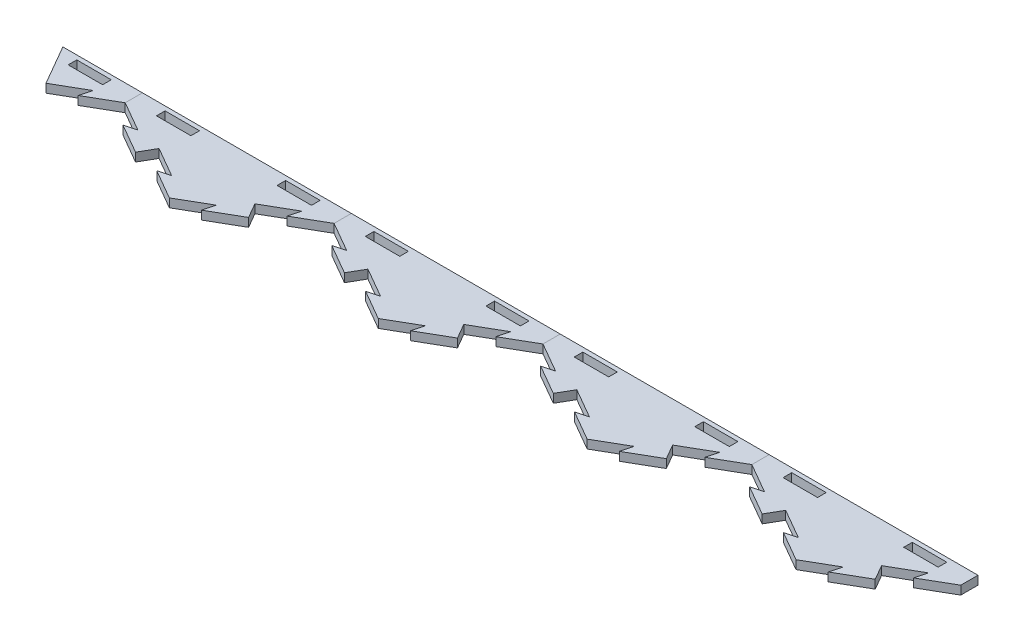
from build123d import *

# Parameters (mm, degrees)
BOSS_EXTRUDE1_DEPTH = 6.35
CUT_EXTRUDE4_DEPTH  = 155.110195964
BOSS_EXTRUDE4_DEPTH = 6.35
CIRPATTERN1_COUNT   = 2
CIRPATTERN1_ANGLE   = 60
SKETCH12_W          = 153.979316792
SKETCH12_H          = 120.65
CUT_EXTRUDE5_DEPTH  = 155.110195964
SKETCH13_W          = 25.4
SKETCH13_H          = 6.35
CUT_EXTRUDE6_DEPTH  = 90.126497182
LPATTERN1_COUNT     = 5
LPATTERN1_PITCH     = 153.979316882
LPATTERN1_2_COUNT   = 2
LPATTERN1_2_PITCH   = 153.979316882
SKETCH14_W          = 25.4
SKETCH14_H          = 6.35
CUT_EXTRUDE7_DEPTH  = 695.360232872
SKETCH15_W          = 58.658787349
SKETCH15_H          = 40.424261314
CUT_EXTRUDE8_DEPTH  = 600.270912242


with BuildPart() as part:
    # Sketch1 → Boss-Extrude1 (new body)
    with BuildSketch(Plane(origin=(0, 0, 0), x_dir=(1, 0, 0), z_dir=(0, 1, 0))):
        Polygon((-76.989658396, 0), (0, -44.45), (76.989658396, 0), (76.989658396, 88.9), (0, 133.35), (-76.989658396, 88.9), align=None)
    extrude(amount=-BOSS_EXTRUDE1_DEPTH)

    # Sketch10 → Cut-Extrude4 (cut, through all)
    with BuildSketch(Plane(origin=(0, 0, 0), x_dir=(1, 0, 0), z_dir=(0, 1, 0))):
        Polygon((-21.997045256, -31.75), (-13.322783942, -29.425738686), (-35.319829198, -16.725738686), (-38.494829198, -22.225), align=None)
    cut_extrude4 = extrude(amount=-CUT_EXTRUDE4_DEPTH, mode=Mode.SUBTRACT)

    # Sketch11 → Boss-Extrude4 (add)
    with BuildSketch(Plane(origin=(0, 0, 0), x_dir=(1, 0, 0), z_dir=(0, 1, 0))):
        Polygon((-38.494829198, -22.225), (-41.669829198, -27.724261314), (-63.666874454, -15.024261314), (-54.99261314, -12.7), align=None)
    boss_extrude4 = extrude(amount=-BOSS_EXTRUDE4_DEPTH)

    # CirPattern1: Cut-Extrude4, Boss-Extrude4 ×2 about axis
    cirpattern1_axis = Axis((0, 0, -44.45), (0, 1, 0))
    add([cut_extrude4.rotate(cirpattern1_axis, i * CIRPATTERN1_ANGLE / (CIRPATTERN1_COUNT - 1)) for i in range(1, CIRPATTERN1_COUNT)], mode=Mode.SUBTRACT)
    add([boss_extrude4.rotate(cirpattern1_axis, i * CIRPATTERN1_ANGLE / (CIRPATTERN1_COUNT - 1)) for i in range(1, CIRPATTERN1_COUNT)])

    # Sketch12 → Cut-Extrude5 (cut, through all)
    with BuildSketch(Plane(origin=(0, 0, 0), x_dir=(1, 0, 0), z_dir=(0, 1, 0))):
        with Locations((0, 73.025)):
            Rectangle(SKETCH12_W, SKETCH12_H)
    extrude(amount=-CUT_EXTRUDE5_DEPTH, mode=Mode.SUBTRACT)

    # Sketch13 → Cut-Extrude6 (cut, through all)
    with BuildSketch(Plane(origin=(0, 0, 0), x_dir=(1, 0, 0), z_dir=(0, 1, 0))):
        with Locations((-44.45, 6.35)):
            Rectangle(SKETCH13_W, SKETCH13_H)
        with Locations((44.45, 6.35)):
            Rectangle(SKETCH13_W, SKETCH13_H)
    extrude(amount=-CUT_EXTRUDE6_DEPTH, mode=Mode.SUBTRACT)


with BuildPart() as lpattern1_1:
    # LPattern1: pattern copy
    add(part.part.moved(Location(Vector(1, 0, 0) * (1 * LPATTERN1_PITCH))))


with BuildPart() as lpattern1_2:
    # LPattern1: pattern copy
    add(part.part.moved(Location(Vector(1, 0, 0) * (2 * LPATTERN1_PITCH))))


with BuildPart() as lpattern1_3:
    # LPattern1: pattern copy
    add(part.part.moved(Location(Vector(1, 0, 0) * (3 * LPATTERN1_PITCH))))


with BuildPart() as lpattern1_4:
    # LPattern1: pattern copy
    add(part.part.moved(Location(Vector(1, 0, 0) * (4 * LPATTERN1_PITCH))))


with BuildPart() as lpattern1_2_1:
    # LPattern1 2: pattern copy
    add(part.part.moved(Location(Vector(-1, 0, 0) * (1 * LPATTERN1_2_PITCH))))


with BuildPart() as cut_extrude7_tool:
    # Sketch14 → Cut-Extrude7 (new, through all)
    # profile 1 of 2: a face of its own
    with BuildSketch(Plane(origin=(0, 0, 0), x_dir=(1, 0, 0), z_dir=(0, 1, 0))):
        Polygon((593.920222272, -31.75), (615.917267528, -44.45), (637.914312784, -31.75), (635.59005147, -40.424261314), (657.587096726, -27.724261314), (651.237096726, -16.725738686), (673.234141982, -4.025738686), (670.909880668, -12.7), (692.906925924, 0), (692.906925924, 12.7), (597.586396481, 12.7), (580.59743833, -16.725738686), (602.594483586, -29.425738686), align=None)
        with Locations((660.367267528, 6.35)):
            Rectangle(SKETCH14_W, SKETCH14_H, mode=Mode.SUBTRACT)
    # profile 2 of 2: a face of its own
    with BuildSketch(Plane(origin=(0, 0, 0), x_dir=(1, 0, 0), z_dir=(0, 1, 0))):
        Polygon((-230.968975278, -44.45), (-153.979316882, -44.45), (-134.30653294, -40.424261314), (-112.309487684, -27.724261314), (-135.648445835, 12.7), (-230.968975278, 12.7), align=None)
    extrude(amount=-CUT_EXTRUDE7_DEPTH)


with BuildPart() as lpattern1_4_1:
    add(lpattern1_4.part)

    # Cut-Extrude7: cut by cut_extrude7_tool
    add(cut_extrude7_tool.part, mode=Mode.SUBTRACT)

    # Sketch15 → Cut-Extrude8 (cut, through all)
    with BuildSketch(Plane(origin=(0, 0, 0), x_dir=(1, 0, 0), z_dir=(0, 1, 0))):
        with Locations((568.257002807, -7.512130657)):
            Rectangle(SKETCH15_W, SKETCH15_H)
    extrude(amount=-CUT_EXTRUDE8_DEPTH, mode=Mode.SUBTRACT)


with BuildPart() as lpattern1_2_1_1:
    add(lpattern1_2_1.part)

    # Cut-Extrude7: cut by cut_extrude7_tool
    add(cut_extrude7_tool.part, mode=Mode.SUBTRACT)


solid = Compound([part.part, lpattern1_1.part, lpattern1_2.part, lpattern1_3.part, lpattern1_2_1_1.part])
